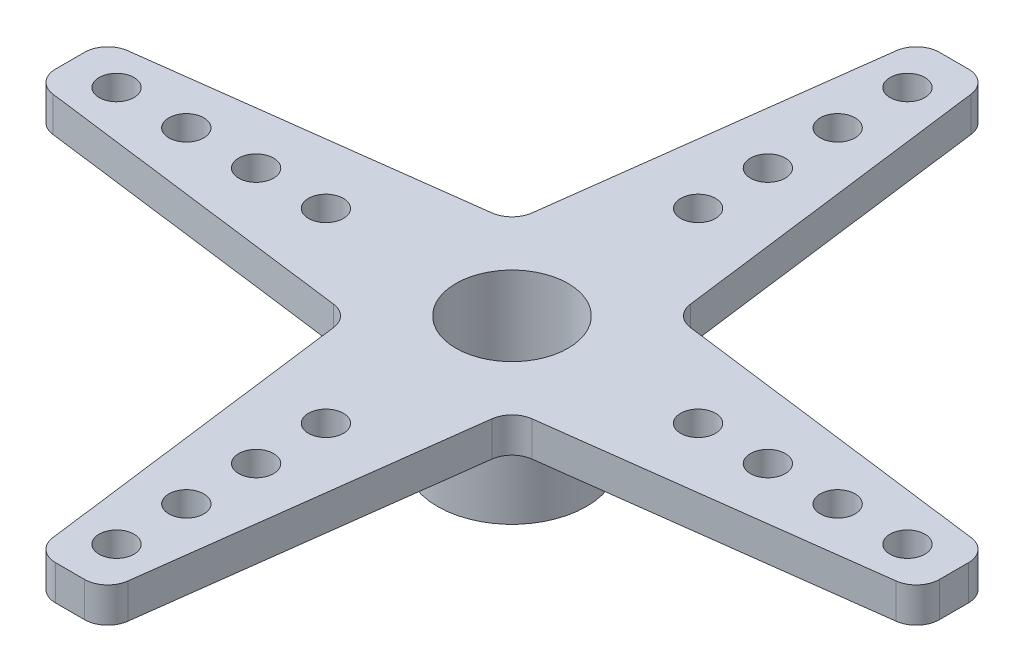
from build123d import *

# Parameters (mm, degrees)
SKETCH1_R           = 2.413
SKETCH1_R_2         = 0.75
BOSS_EXTRUDE1_DEPTH = 1.5
SKETCH2_R           = 3.2
SKETCH2_R_2         = 2.413
BOSS_EXTRUDE2_DEPTH = 4
FILLET1_R           = 1


with BuildPart() as part:
    # Sketch1 → Boss-Extrude1 (new body)
    with BuildSketch(Plane(origin=(0, 0, 0), x_dir=(1, 0, 0), z_dir=(0, 1, 0))):
        Polygon((-1.5, 19), (-3.5, 3.5), (-19, 1.5), (-19, -1.5), (-3.5, -3.5), (-1.5, -19), (1.5, -19), (3.5, -3.5), (19, -1.5), (19, 1.5), (3.5, 3.5), (1.5, 19), align=None)
        Circle(SKETCH1_R, mode=Mode.SUBTRACT)
        with Locations((8, 0)):
            Circle(SKETCH1_R_2, mode=Mode.SUBTRACT)
        with Locations((11, 0)):
            Circle(SKETCH1_R_2, mode=Mode.SUBTRACT)
        with Locations((14, 0)):
            Circle(SKETCH1_R_2, mode=Mode.SUBTRACT)
        with Locations((17, 0)):
            Circle(SKETCH1_R_2, mode=Mode.SUBTRACT)
        with Locations((0, -8)):
            Circle(SKETCH1_R_2, mode=Mode.SUBTRACT)
        with Locations((0, -11)):
            Circle(SKETCH1_R_2, mode=Mode.SUBTRACT)
        with Locations((0, -14)):
            Circle(SKETCH1_R_2, mode=Mode.SUBTRACT)
        with Locations((0, -17)):
            Circle(SKETCH1_R_2, mode=Mode.SUBTRACT)
        with Locations((-8, 0)):
            Circle(SKETCH1_R_2, mode=Mode.SUBTRACT)
        with Locations((-11, 0)):
            Circle(SKETCH1_R_2, mode=Mode.SUBTRACT)
        with Locations((-14, 0)):
            Circle(SKETCH1_R_2, mode=Mode.SUBTRACT)
        with Locations((-17, 0)):
            Circle(SKETCH1_R_2, mode=Mode.SUBTRACT)
        with Locations((0, 8)):
            Circle(SKETCH1_R_2, mode=Mode.SUBTRACT)
        with Locations((0, 11)):
            Circle(SKETCH1_R_2, mode=Mode.SUBTRACT)
        with Locations((0, 14)):
            Circle(SKETCH1_R_2, mode=Mode.SUBTRACT)
        with Locations((0, 17)):
            Circle(SKETCH1_R_2, mode=Mode.SUBTRACT)
    extrude(amount=BOSS_EXTRUDE1_DEPTH)

    # Sketch2 → Boss-Extrude2 (add)
    with BuildSketch(Plane.XZ):
        Circle(SKETCH2_R)
        Circle(SKETCH2_R_2, mode=Mode.SUBTRACT)
    extrude(amount=BOSS_EXTRUDE2_DEPTH)

    # Fillet1
    fillet1_edges = [part.edges().sort_by_distance(p)[0] for p in [
        (-1.5, 0.75, 19),
        (-3.5, 0.75, 3.5),
        (-19, 0.75, 1.5),
        (-19, 0.75, -1.5),
        (-3.5, 0.75, -3.5),
        (-1.5, 0.75, -19),
        (1.5, 0.75, -19),
        (3.5, 0.75, -3.5),
        (19, 0.75, -1.5),
        (19, 0.75, 1.5),
        (3.5, 0.75, 3.5),
        (1.5, 0.75, 19),
    ]]
    fillet(fillet1_edges, radius=FILLET1_R)


solid = part.part
